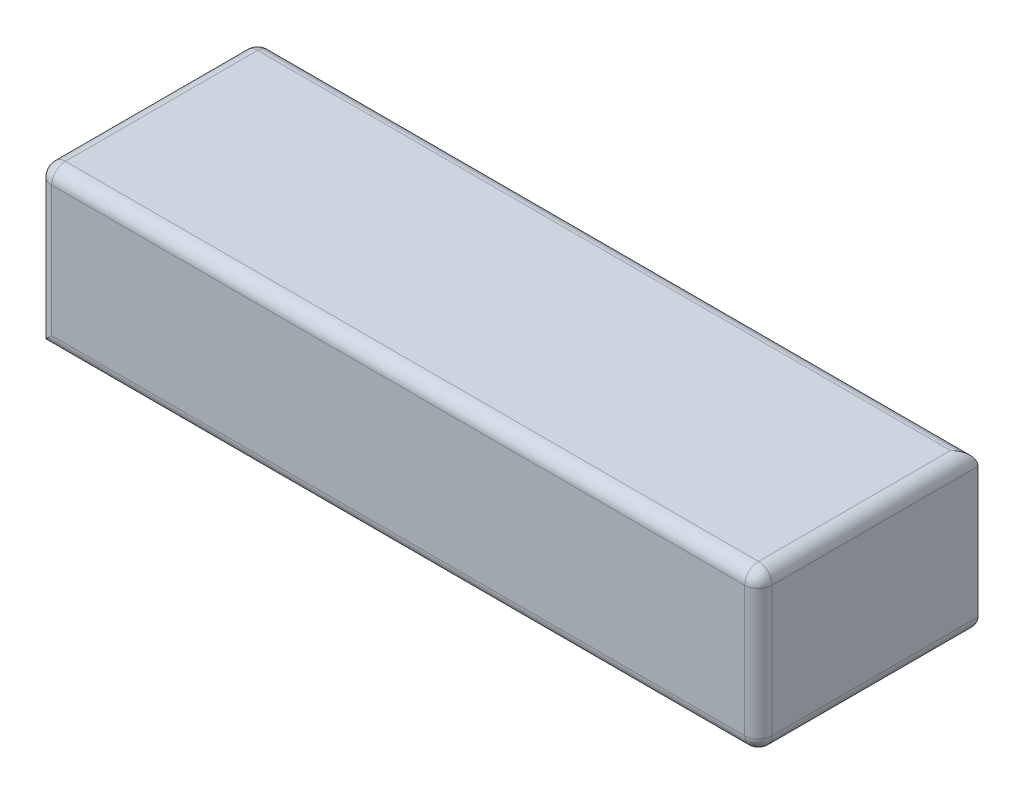
from build123d import *

# Parameters (mm, degrees)
SKETCH1_W           = 105
SKETCH1_H           = 32
BOSS_EXTRUDE1_DEPTH = 23
FILLET1_R           = 2


with BuildPart() as part:
    # Sketch1 → Boss-Extrude1 (new body)
    with BuildSketch(Plane(origin=(0, 0, 0), x_dir=(1, 0, 0), z_dir=(0, 1, 0))):
        Rectangle(SKETCH1_W, SKETCH1_H)
    extrude(amount=BOSS_EXTRUDE1_DEPTH)

    # Fillet1
    fillet1_edges = [part.edges().sort_by_distance(p)[0] for p in [
        (-52.5, 23, 0),
        (0, 23, 16),
        (52.5, 23, 0),
        (0, 0, 16),
        (0, 0, -16),
        (52.5, 0, 0),
        (0, 23, -16),
        (52.5, 11.5, 16),
        (-52.5, 11.5, 16),
        (-52.5, 11.5, -16),
    ]]
    fillet(fillet1_edges, radius=FILLET1_R)


solid = part.part
